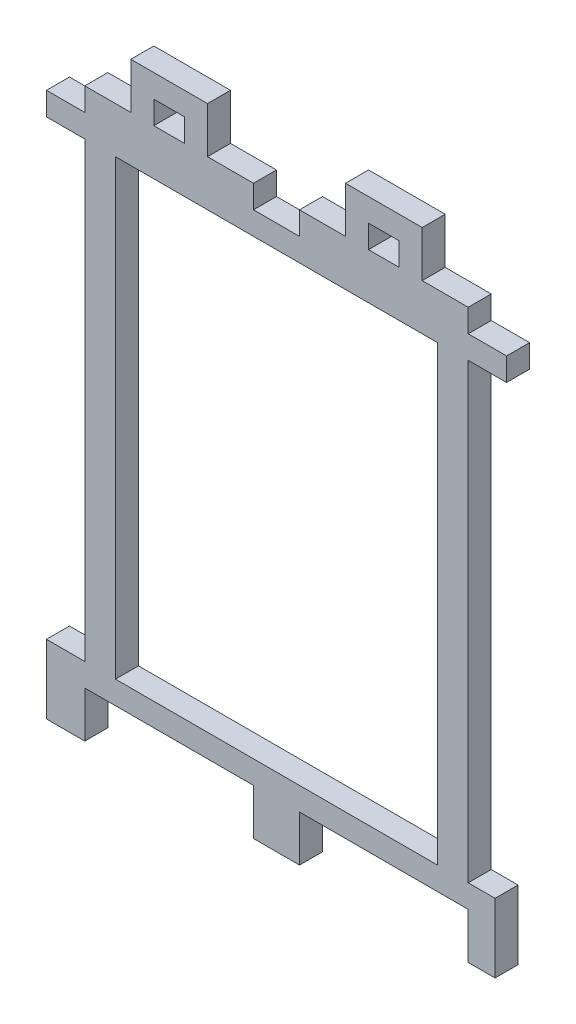
from build123d import *

# Parameters (mm, degrees)
SKETCH1_W           = 42
SKETCH1_H           = 59
BOSS_EXTRUDE1_DEPTH = 3
BOSS_EXTRUDE2_DEPTH = 3


with BuildPart() as part:
    # Sketch1 → Boss-Extrude1 (new body)
    with BuildSketch(Plane.XY):
        Polygon((0, 0), (5, 0), (5, 3), (27, 3), (27, 0), (33, 0), (33, 3), (55, 3), (55, 0), (60, 0), (60, -3), (55, -3), (55, -62), (58.5, -62), (58.5, -71), (55, -71), (55, -65), (33, -65), (33, -71), (27, -71), (27, -65), (5, -65), (5, -71), (0, -71), (0, -62), (5, -62), (5, -3), (0, -3), align=None)
        with Locations((30, -32.5)):
            Rectangle(SKETCH1_W, SKETCH1_H, mode=Mode.SUBTRACT)
    extrude(amount=BOSS_EXTRUDE1_DEPTH)

    # Sketch2 → Boss-Extrude2 (add)
    with BuildSketch(Plane(origin=(0, 0, 0), x_dir=(-1, 0, 0), z_dir=(0, 0, -1))):
        Polygon((-49, 9), (-49, 3), (-46, 3), (-46, 6), (-42, 6), (-42, 3), (-39, 3), (-39, 9), align=None)
        Polygon((-21, 3), (-18, 3), (-18, 6), (-14, 6), (-14, 3), (-11, 3), (-11, 9), (-21, 9), align=None)
    extrude(amount=-BOSS_EXTRUDE2_DEPTH)


solid = part.part
